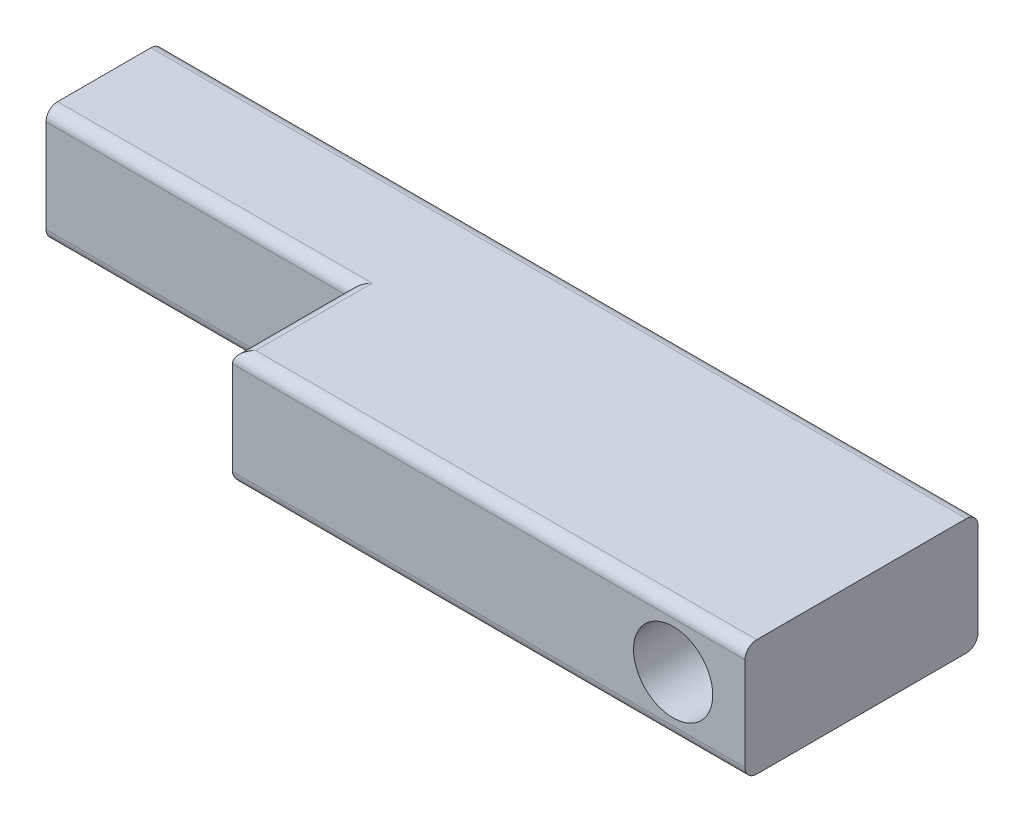
from build123d import *

# Parameters (mm, degrees)
SKETCH1_W            = 35
SKETCH1_H            = 5
BOSS_EXTRUDE1_DEPTH  = 5
SKETCH3_W            = 22
SKETCH3_H            = 5
BOSS_EXTRUDE3_DEPTH  = 5
FILLET1_R            = 0.5
M3_CLEARANCE_HOLE1_D = 3.4


with BuildPart() as part:
    # Sketch1 → Boss-Extrude1 (new body)
    with BuildSketch(Plane.XY):
        Rectangle(SKETCH1_W, SKETCH1_H)
    extrude(amount=BOSS_EXTRUDE1_DEPTH)

    # Sketch3 → Boss-Extrude3 (add)
    with BuildSketch(Plane.XY.offset(5)):
        with Locations((6.5, 0)):
            Rectangle(SKETCH3_W, SKETCH3_H)
    extrude(amount=BOSS_EXTRUDE3_DEPTH)

    # Fillet1
    fillet1_edges = [part.edges().sort_by_distance(p)[0] for p in [
        (-11, 2.5, 5),
        (-4.5, 2.5, 7.5),
        (-4.5, -2.5, 7.5),
        (-11, -2.5, 5),
        (6.5, 2.5, 10),
        (6.5, -2.5, 10),
        (0, -2.5, 0),
        (0, 2.5, 0),
    ]]
    fillet(fillet1_edges, radius=FILLET1_R)

    # M3 Clearance Hole1 (through all)
    with Locations(Plane(origin=(14.415303624, 0, 0), x_dir=(-1, 0, 0), z_dir=(0, 0, -1))):
        with Locations((0, 0)):
            Hole(M3_CLEARANCE_HOLE1_D / 2)


solid = part.part
